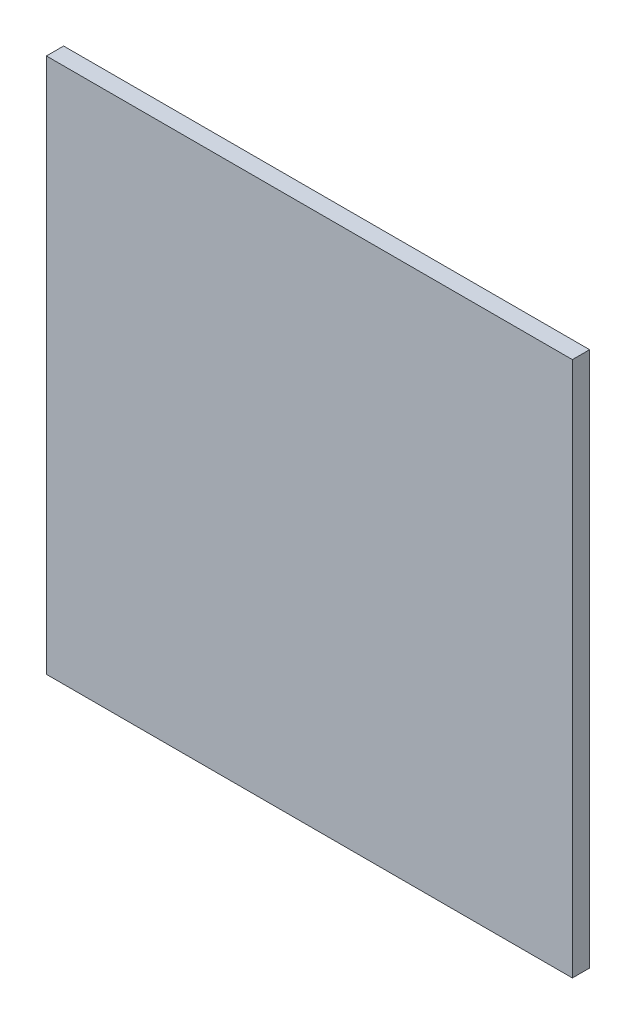
from build123d import *

# Parameters (mm, degrees)
SKETCH1_W           = 550
SKETCH1_H           = 560
BOSS_EXTRUDE1_DEPTH = 18


with BuildPart() as part:
    # Sketch1 → Boss-Extrude1 (new body)
    with BuildSketch(Plane.XY):
        Rectangle(SKETCH1_W, SKETCH1_H)
    extrude(amount=BOSS_EXTRUDE1_DEPTH)


solid = part.part
